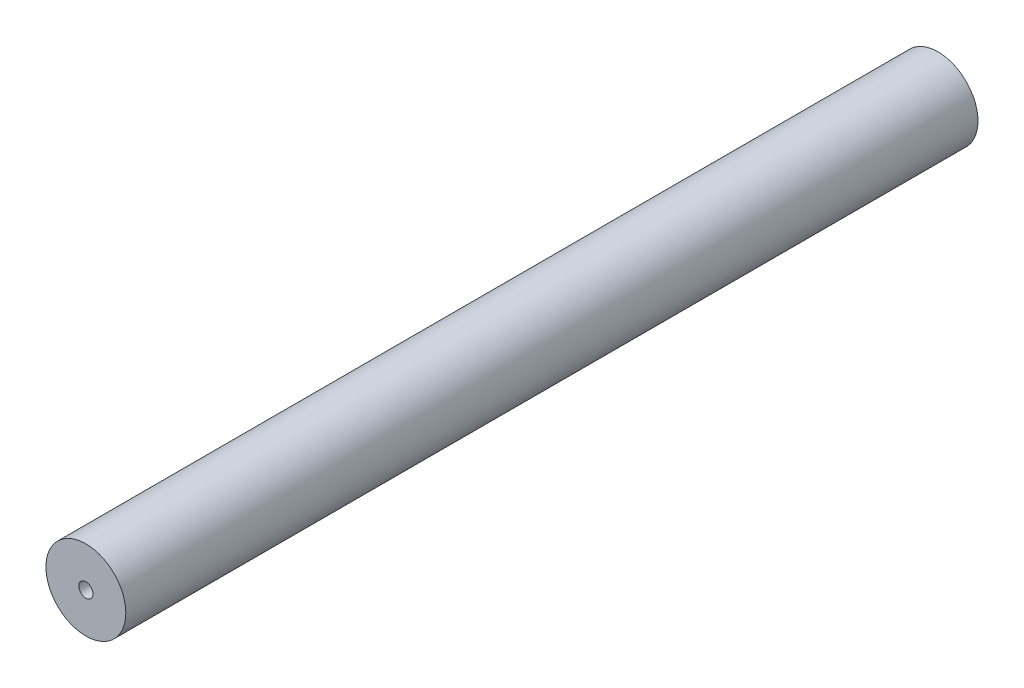
from build123d import *

# Parameters (mm, degrees)
SKETCH1_R           = 2.25
SKETCH1_R_2         = 0.4
BOSS_EXTRUDE1_DEPTH = 48


with BuildPart() as part:
    # Sketch1 → Boss-Extrude1 (new body)
    with BuildSketch(Plane.XY):
        Circle(SKETCH1_R)
        Circle(SKETCH1_R_2, mode=Mode.SUBTRACT)
    extrude(amount=BOSS_EXTRUDE1_DEPTH)


solid = part.part
